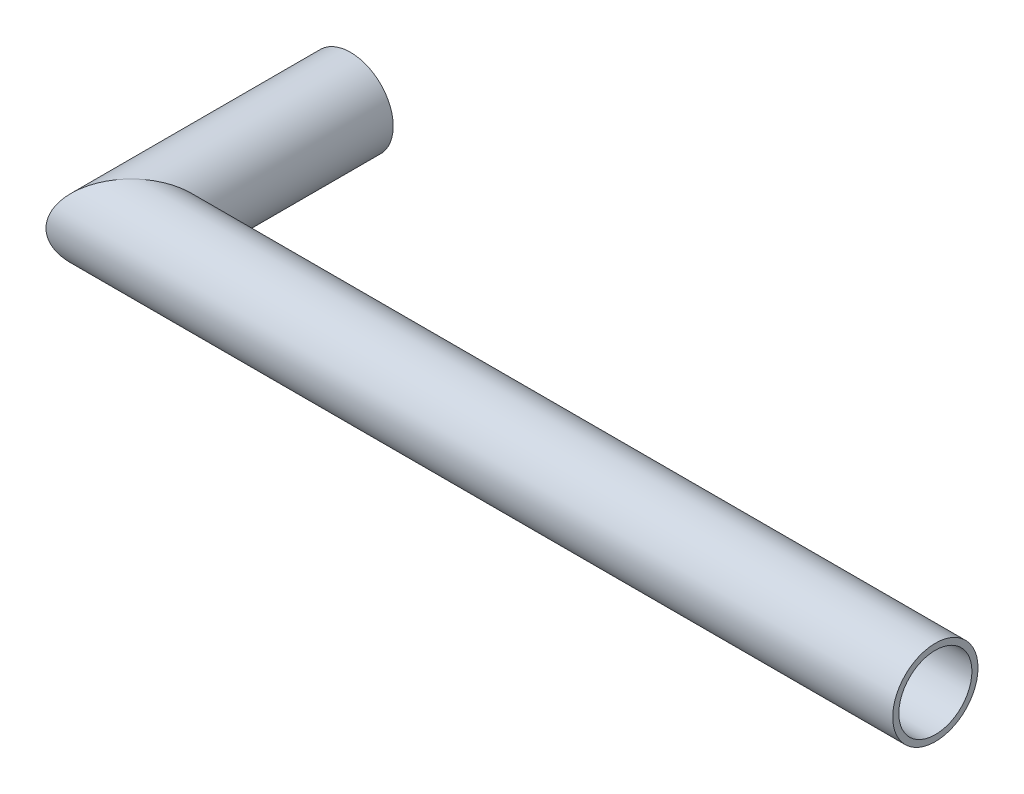
from build123d import *

# Parameters (mm, degrees)
SKETCH2_R   = 35
SKETCH2_R_2 = 30


with BuildPart() as part:
    # Sweep-Thin1: sweep along a path in Sketch1
    with BuildLine(Plane(origin=(0, 0, 0), x_dir=(1, 0, 0), z_dir=(0, 1, 0))) as sweep_thin1_path:
        Line((0, 180), (0, 0))
        Line((0, 0), (660, 0))
    # Sketch2 → Sweep-Thin1 (sweep)
    with BuildSketch(Plane.XY.offset(-180)):
        Circle(SKETCH2_R)
        Circle(SKETCH2_R_2, mode=Mode.SUBTRACT)
    sweep(path=sweep_thin1_path.line, transition=Transition.RIGHT)


solid = part.part
